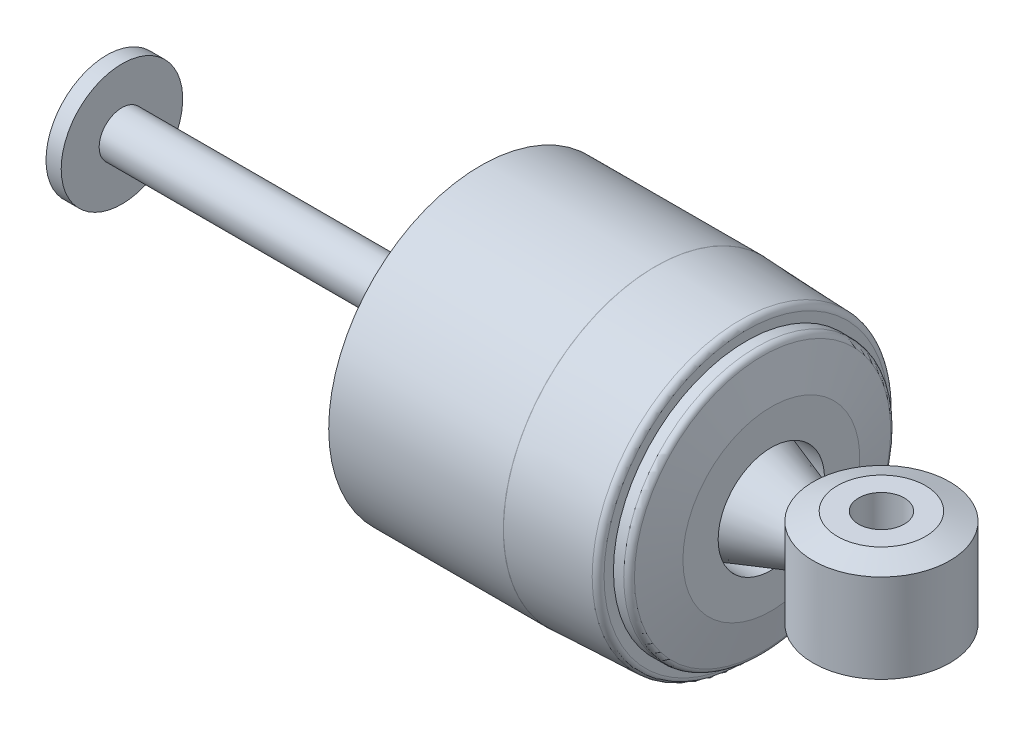
from build123d import *
from OCP.BRepFilletAPI import BRepFilletAPI_MakeChamfer

# Parameters (mm, degrees)
SKETCH2_R           = 14.2875
SKETCH2_R_2         = 4.7625
BOSS_EXTRUDE1_DEPTH = 11.1125
CHAMFER1_SIZE       = 5.08
CHAMFER1_SIZE2      = 1.84896879
FILLET1_R           = 1.27


with BuildPart() as part:
    # Sketch1 → Revolve1 (revolve)
    with BuildSketch(Plane(origin=(0, 0, 0), x_dir=(1, 0, 0), z_dir=(0, 1, 0)), mode=Mode.PRIVATE) as revolve1_sk:
        Polygon((-68.007276158, 20.214239498), (-68.007276158, 7.514239498), (81.344723842, 7.514239498), (81.344723842, 13.229239498), (65.342723842, 18.626739498), (65.342723842, 12.276739498), (-64.832276158, 12.276739498), (-64.832276158, 20.214239498), align=None)
    revolve(revolve1_sk.sketch.rotate(Axis((-68.007276158, 0, -7.514239498), (1, 0, 0)), 180), axis=Axis((-68.007276158, 0, -7.514239498), (1, 0, 0)))

    # Sketch3 → Revolve2 (revolve)
    with BuildSketch(Plane(origin=(0, 0, 0), x_dir=(1, 0, 0), z_dir=(0, 1, 0)), mode=Mode.PRIVATE) as revolve2_sk:
        Polygon((65.342723842, 12.276739498), (65.342723842, 18.626739498), (70.898973842, 18.626739498), (70.898973842, 25.992739498), (68.853376756, 35.295489498), (65.678376756, 35.295489498), (65.678376756, 38.470489498), (46.644920398, 39.264239498), (10.132420398, 39.264239498), (10.132420398, 38.470489498), (46.628376756, 38.470489498), (59.943625033, 37.915205259), (64.548973842, 28.923216622), (64.548973842, 12.276739498), align=None)
        Polygon((64.548973842, 2.751739498), (65.342723842, 2.751739498), (65.342723842, -3.598260502), (70.898973842, -3.598260502), (70.898973842, -10.964260502), (68.853376756, -20.267010502), (65.678376756, -20.267010502), (65.678376756, -23.442010502), (46.644920398, -24.235760502), (10.132420398, -24.235760502), (10.132420398, -23.442010502), (46.628376756, -23.442010502), (59.943625033, -22.886726264), (64.548973842, -13.894737626), align=None)
    revolve(revolve2_sk.sketch.rotate(Axis((-68.086651194, 0, -7.514239498), (1, 0, 0)), 180), axis=Axis((-68.086651194, 0, -7.514239498), (1, 0, 0)))

    # Fillet1
    fillet1_edges = [part.edges().sort_by_distance(p)[0] for p in [
        (68.853376756, 0, -35.295489498),
        (65.678376756, 0, -38.470489498),
        (46.644920398, 0, -39.264239498),
    ]]
    fillet(fillet1_edges, radius=FILLET1_R)


with BuildPart() as body_2:
    # Sketch2 → Boss-Extrude1 (new, symmetric)
    with BuildSketch(Plane(origin=(0, 0, 0), x_dir=(1, 0, 0), z_dir=(0, 1, 0))):
        with Locations(Location((93.917723842, 7.514239498, 0), (0, 0, 270))):
            Circle(SKETCH2_R)
        with Locations(Location((93.917723842, 7.514239498, 0), (0, 0, 270))):
            Circle(SKETCH2_R_2, mode=Mode.SUBTRACT)
    extrude(amount=BOSS_EXTRUDE1_DEPTH, both=True)

    # Chamfer1: one chamfer whose edges measure the first distance from different faces: ONE call of the kernel's chamfer builder (chamfer() names one face for all edges)
    chamfer1_edges_1 = [body_2.edges().sort_by_distance(p)[0] for p in [
        (93.917723842, -11.1125, -21.801739498),
    ]]
    chamfer1_side_1 = [body_2.faces().sort_by_distance(p)[0] for p in [
        (93.917723842, -11.1125, -21.397627972),
    ]]
    chamfer1_edges_2 = [body_2.edges().sort_by_distance(p)[0] for p in [
        (93.917723842, 11.1125, -21.801739498),
    ]]
    chamfer1_side_2 = [body_2.faces().sort_by_distance(p)[0] for p in [
        (93.917723842, 11.1125, -21.397627972),
    ]]
    chamfer1 = BRepFilletAPI_MakeChamfer(body_2.part.solid().wrapped)
    for e in chamfer1_edges_1:
        chamfer1.Add(CHAMFER1_SIZE, CHAMFER1_SIZE2, e.wrapped, chamfer1_side_1[0].wrapped)  # the first distance lies on this face
    for e in chamfer1_edges_2:
        chamfer1.Add(CHAMFER1_SIZE, CHAMFER1_SIZE2, e.wrapped, chamfer1_side_2[0].wrapped)  # the first distance lies on this face
    add(Compound.cast(chamfer1.Shape()), mode=Mode.REPLACE)


solid = Compound([part.part, body_2.part])
